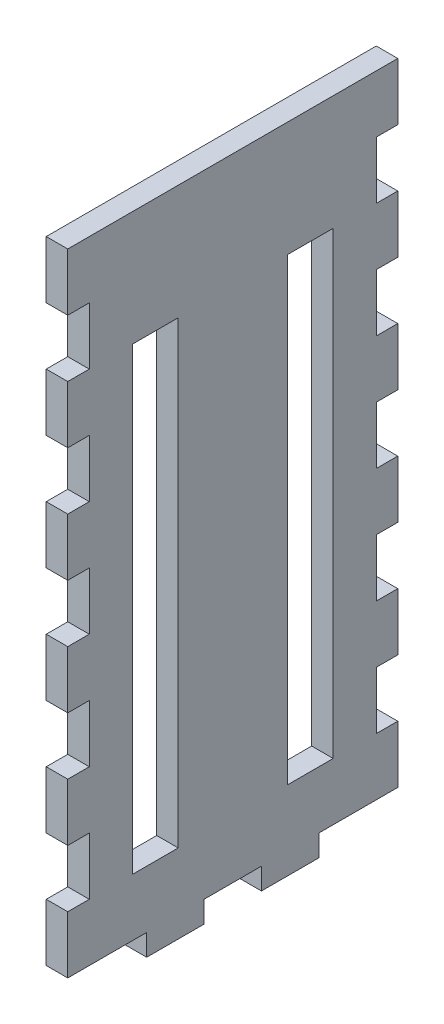
from build123d import *

# Parameters (mm, degrees)
SKETCH1_W               = 127
SKETCH1_H               = 279.4
BOSS_EXTRUDE1_DEPTH     = 9.525
SKETCH2_W               = 9.525
SKETCH2_H               = 25.4
BOSS_EXTRUDE2_DEPTH     = 9.525
LPATTERN1_COUNT         = 6
LPATTERN1_PITCH         = 50.8
MIRROR1_COPY_1_SKETCH_W = 9.525
MIRROR1_COPY_1_SKETCH_H = 25.4
MIRROR1_COPY_1_DEPTH    = 9.525
MIRROR1_COPY_2_SKETCH_W = 9.525
MIRROR1_COPY_2_SKETCH_H = 25.4
MIRROR1_COPY_2_DEPTH    = 9.525
MIRROR1_COPY_3_SKETCH_W = 9.525
MIRROR1_COPY_3_SKETCH_H = 25.4
MIRROR1_COPY_3_DEPTH    = 9.525
MIRROR1_COPY_4_SKETCH_W = 9.525
MIRROR1_COPY_4_SKETCH_H = 25.4
MIRROR1_COPY_4_DEPTH    = 9.525
MIRROR1_COPY_5_SKETCH_W = 9.525
MIRROR1_COPY_5_SKETCH_H = 25.4
MIRROR1_COPY_5_DEPTH    = 9.525
SKETCH3_W               = 9.525
SKETCH3_H               = 25.4
BOSS_EXTRUDE3_DEPTH     = 9.525
LPATTERN2_COUNT         = 2
LPATTERN2_PITCH         = 50.8
SKETCH4_W               = 20.32
SKETCH4_H               = 203.2
CUT_EXTRUDE1_DEPTH      = 9.525


with BuildPart() as part:
    # Sketch1 → Boss-Extrude1 (new body)
    with BuildSketch(Plane(origin=(0, 0, 0), x_dir=(0, 0, -1), z_dir=(1, 0, 0))):
        Rectangle(SKETCH1_W, SKETCH1_H)
    extrude(amount=BOSS_EXTRUDE1_DEPTH)

    # Sketch2 → Boss-Extrude2 (add)
    with BuildSketch(Plane.XY.offset(63.5)):
        with Locations((4.7625, 127)):
            Rectangle(SKETCH2_W, SKETCH2_H)
    boss_extrude2 = extrude(amount=BOSS_EXTRUDE2_DEPTH)

    # LPattern1: Boss-Extrude2 ×6
    with Locations(*[(0, -i * LPATTERN1_PITCH, 0) for i in range(1, LPATTERN1_COUNT)]):
        add(boss_extrude2)

    # Mirror1: Boss-Extrude2 across plane
    add(boss_extrude2.mirror(Plane.XY))

    # Mirror1 copy 1 sketch → Mirror1 copy 1 (add)
    with BuildSketch(Plane(origin=(0, -50.8, -63.5), x_dir=(1, 0, 0), z_dir=(0, 0, -1))):
        with Locations((4.7625, -127)):
            Rectangle(MIRROR1_COPY_1_SKETCH_W, MIRROR1_COPY_1_SKETCH_H)
    extrude(amount=MIRROR1_COPY_1_DEPTH)

    # Mirror1 copy 2 sketch → Mirror1 copy 2 (add)
    with BuildSketch(Plane(origin=(0, -101.6, -63.5), x_dir=(1, 0, 0), z_dir=(0, 0, -1))):
        with Locations((4.7625, -127)):
            Rectangle(MIRROR1_COPY_2_SKETCH_W, MIRROR1_COPY_2_SKETCH_H)
    extrude(amount=MIRROR1_COPY_2_DEPTH)

    # Mirror1 copy 3 sketch → Mirror1 copy 3 (add)
    with BuildSketch(Plane(origin=(0, -152.4, -63.5), x_dir=(1, 0, 0), z_dir=(0, 0, -1))):
        with Locations((4.7625, -127)):
            Rectangle(MIRROR1_COPY_3_SKETCH_W, MIRROR1_COPY_3_SKETCH_H)
    extrude(amount=MIRROR1_COPY_3_DEPTH)

    # Mirror1 copy 4 sketch → Mirror1 copy 4 (add)
    with BuildSketch(Plane(origin=(0, -203.2, -63.5), x_dir=(1, 0, 0), z_dir=(0, 0, -1))):
        with Locations((4.7625, -127)):
            Rectangle(MIRROR1_COPY_4_SKETCH_W, MIRROR1_COPY_4_SKETCH_H)
    extrude(amount=MIRROR1_COPY_4_DEPTH)

    # Mirror1 copy 5 sketch → Mirror1 copy 5 (add)
    with BuildSketch(Plane(origin=(0, -254, -63.5), x_dir=(1, 0, 0), z_dir=(0, 0, -1))):
        with Locations((4.7625, -127)):
            Rectangle(MIRROR1_COPY_5_SKETCH_W, MIRROR1_COPY_5_SKETCH_H)
    extrude(amount=MIRROR1_COPY_5_DEPTH)

    # Sketch3 → Boss-Extrude3 (add)
    with BuildSketch(Plane.XZ.offset(139.7)):
        with Locations((4.7625, 25.4)):
            Rectangle(SKETCH3_W, SKETCH3_H)
    boss_extrude3 = extrude(amount=BOSS_EXTRUDE3_DEPTH)

    # LPattern2: Boss-Extrude3 ×2
    with Locations(*[(0, 0, -i * LPATTERN2_PITCH) for i in range(1, LPATTERN2_COUNT)]):
        add(boss_extrude3)

    # Sketch4 → Cut-Extrude1 (cut)
    with BuildSketch(Plane(origin=(9.525, 0, 0), x_dir=(0, 0, -1), z_dir=(1, 0, 0))):
        with Locations((-34.29, -12.7)):
            Rectangle(SKETCH4_W, SKETCH4_H)
    cut_extrude1 = extrude(amount=-CUT_EXTRUDE1_DEPTH, mode=Mode.SUBTRACT)

    # Mirror2: Cut-Extrude1 across plane
    add(cut_extrude1.mirror(Plane.XY), mode=Mode.SUBTRACT)


solid = part.part
